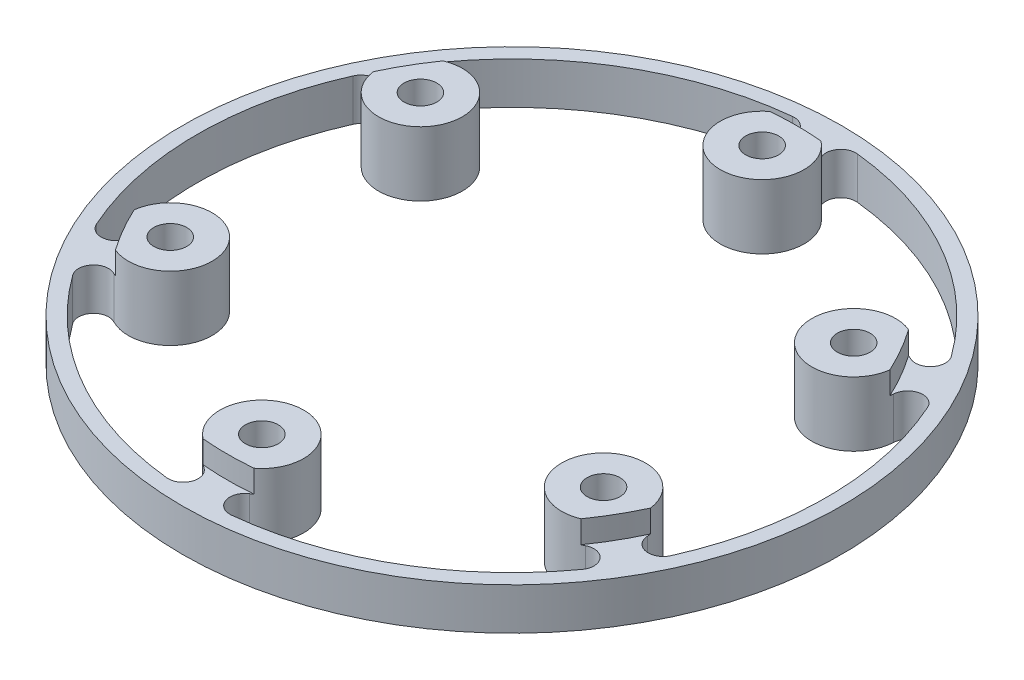
from build123d import *

# Parameters (mm, degrees)
SKETCH1_R             = 22
BASE_SHAPE_DEPTH      = 4.3
BASE_CUT_REACH        = 33.408
SKETCH4_R             = 2.1
MILLING_FILLETS_R     = 1
MIDDLE_START          = -1.5
SKETCH5_R             = 22
SKETCH5_R_2           = 19
MIDDLE_SLOT_CUT_DEPTH = 1.5
M2_SCREW_HOLES_REACH  = 33.408
SKETCH6_R             = 1.1
REMOVE_INNER_REACH    = 33.408


with BuildPart() as part:
    # Sketch1 → Base shape (new body)
    with BuildSketch(Plane(origin=(0, 0, 0), x_dir=(1, 0, 0), z_dir=(0, 1, 0))):
        Circle(SKETCH1_R)
    extrude(amount=BASE_SHAPE_DEPTH)

    # Sketch4 → Base cut (cut, up to next)
    with BuildSketch(Plane(origin=(0, 4.3, 0), x_dir=(1, 0, 0), z_dir=(0, 1, 0)), mode=Mode.PRIVATE) as base_cut_sk1:
        with BuildLine():
            Line((-0.5, 4.623040125), (-0.5, 13.945004537))
            ThreePointArc((-0.5, 13.945004537), (-2.746076212, 16.153131244), (-1.517286534, 19.053261901))
            ThreePointArc((-1.517286534, 19.053261901), (-1.115725557, 20.225230181), (-2.162133235, 20.888398212))
            ThreePointArc((-2.162133235, 20.888398212), (-10.500000003, 18.186533478), (-17.008816883, 12.316661408))
            ThreePointArc((-17.008816883, 12.316661408), (-16.957700355, 11.078861766), (-15.74196557, 10.84063963))
            ThreePointArc((-15.74196557, 10.84063963), (-12.615983904, 10.454737385), (-11.826728185, 7.40551497))
            Line((-11.826728185, 7.40551497), (-3.753670191, 2.744532765))
            ThreePointArc((-3.753670191, 2.744532765), (-2.325, 4.027018128), (-0.5, 4.623040125))
        make_face()
    base_cut_tool1 = extrude(base_cut_sk1.sketch, amount=-BASE_CUT_REACH, mode=Mode.PRIVATE) & part.part
    # Sketch4 → Base cut (cut, up to next)
    with BuildSketch(Plane(origin=(0, 4.3, 0), x_dir=(1, 0, 0), z_dir=(0, 1, 0)), mode=Mode.PRIVATE) as base_cut_sk2:
        with BuildLine():
            Line((0.5, 13.945004537), (0.5, 4.623040125))
            ThreePointArc((0.5, 4.623040125), (2.325, 4.027018128), (3.753670191, 2.744532765))
            Line((3.753670191, 2.744532765), (11.826728185, 7.40551497))
            ThreePointArc((11.826728185, 7.40551497), (12.615983941, 10.454737417), (15.741965657, 10.840639586))
            ThreePointArc((15.741965657, 10.840639586), (16.957700372, 11.078861786), (17.00881691, 12.316661371))
            ThreePointArc((17.00881691, 12.316661371), (10.500000058, 18.186533446), (2.162133314, 20.888398204))
            ThreePointArc((2.162133314, 20.888398204), (1.11572557, 20.225230219), (1.517286532, 19.053261902))
            ThreePointArc((1.517286532, 19.053261902), (2.746076212, 16.153131245), (0.5, 13.945004537))
        make_face()
    base_cut_tool2 = extrude(base_cut_sk2.sketch, amount=-BASE_CUT_REACH, mode=Mode.PRIVATE) & part.part
    # Sketch4 → Base cut (cut, up to next)
    with BuildSketch(Plane(origin=(0, 4.3, 0), x_dir=(1, 0, 0), z_dir=(0, 1, 0)), mode=Mode.PRIVATE) as base_cut_sk3:
        with BuildLine():
            ThreePointArc((-4.253670191, -1.878507361), (-4.65, 0), (-4.253670191, 1.878507361))
            Line((-4.253670191, 1.878507361), (-12.326728185, 6.539489567))
            ThreePointArc((-12.326728185, 6.539489567), (-15.362060141, 5.698393871), (-17.259252101, 8.212622326))
            ThreePointArc((-17.259252101, 8.212622326), (-18.073426017, 9.146368434), (-19.170950177, 8.571736657))
            ThreePointArc((-19.170950177, 8.571736657), (-21, -2.3e-08), (-19.170950158, -8.571736698))
            ThreePointArc((-19.170950158, -8.571736698), (-18.073425944, -9.146368421), (-17.259252096, -8.212622223))
            ThreePointArc((-17.259252096, -8.212622223), (-15.362060093, -5.698393854), (-12.326728185, -6.539489567))
            Line((-12.326728185, -6.539489567), (-4.253670191, -1.878507361))
        make_face()
    base_cut_tool3 = extrude(base_cut_sk3.sketch, amount=-BASE_CUT_REACH, mode=Mode.PRIVATE) & part.part
    # Sketch4 → Base cut (cut, up to next)
    with BuildSketch(Plane(origin=(0, 4.3, 0), x_dir=(1, 0, 0), z_dir=(0, 1, 0)), mode=Mode.PRIVATE) as base_cut_sk4:
        with BuildLine():
            Line((12.326728185, 6.539489567), (4.253670191, 1.878507361))
            ThreePointArc((4.253670191, 1.878507361), (4.65, 0), (4.253670191, -1.878507361))
            Line((4.253670191, -1.878507361), (12.326728185, -6.539489567))
            ThreePointArc((12.326728185, -6.539489567), (15.362060141, -5.698393871), (17.259252101, -8.212622326))
            ThreePointArc((17.259252101, -8.212622326), (18.07342595, -9.146368422), (19.170950121, -8.571736781))
            ThreePointArc((19.170950121, -8.571736781), (21, -9e-09), (19.170950128, 8.571736765))
            ThreePointArc((19.170950128, 8.571736765), (18.073425908, 9.146368414), (17.259252096, 8.212622223))
            ThreePointArc((17.259252096, 8.212622223), (15.362060093, 5.698393854), (12.326728185, 6.539489567))
        make_face()
    base_cut_tool4 = extrude(base_cut_sk4.sketch, amount=-BASE_CUT_REACH, mode=Mode.PRIVATE) & part.part
    # Sketch4 → Base cut (cut, up to next)
    with BuildSketch(Plane(origin=(0, 4.3, 0), x_dir=(1, 0, 0), z_dir=(0, 1, 0)), mode=Mode.PRIVATE) as base_cut_sk5:
        with BuildLine():
            ThreePointArc((-0.5, -4.623040125), (-2.325, -4.027018128), (-3.753670191, -2.744532765))
            Line((-3.753670191, -2.744532765), (-11.826728185, -7.40551497))
            ThreePointArc((-11.826728185, -7.40551497), (-12.615983918, -10.454737397), (-15.741965602, -10.840639614))
            ThreePointArc((-15.741965602, -10.840639614), (-16.957700382, -11.078861797), (-17.008816856, -12.316661445))
            ThreePointArc((-17.008816856, -12.316661445), (-10.500000018, -18.186533469), (-2.162133314, -20.888398204))
            ThreePointArc((-2.162133314, -20.888398204), (-1.115725572, -20.225230224), (-1.517286523, -19.053261908))
            ThreePointArc((-1.517286523, -19.053261908), (-2.746076213, -16.15313125), (-0.5, -13.945004537))
            Line((-0.5, -13.945004537), (-0.5, -4.623040125))
        make_face()
    base_cut_tool5 = extrude(base_cut_sk5.sketch, amount=-BASE_CUT_REACH, mode=Mode.PRIVATE) & part.part
    # Sketch4 → Base cut (cut, up to next)
    with BuildSketch(Plane(origin=(0, 4.3, 0), x_dir=(1, 0, 0), z_dir=(0, 1, 0)), mode=Mode.PRIVATE) as base_cut_sk6:
        with BuildLine():
            Line((11.826728185, -7.40551497), (3.753670191, -2.744532765))
            ThreePointArc((3.753670191, -2.744532765), (2.325, -4.027018128), (0.5, -4.623040125))
            Line((0.5, -4.623040125), (0.5, -13.945004537))
            ThreePointArc((0.5, -13.945004537), (2.746076211, -16.15313124), (1.51728654, -19.053261897))
            ThreePointArc((1.51728654, -19.053261897), (1.115725569, -20.225230215), (2.162133314, -20.888398204))
            ThreePointArc((2.162133314, -20.888398204), (10.499999986, -18.186533488), (17.008816813, -12.316661505))
            ThreePointArc((17.008816813, -12.316661505), (16.957700403, -11.078861822), (15.741965594, -10.840639618))
            ThreePointArc((15.741965594, -10.840639618), (12.615983914, -10.454737394), (11.826728185, -7.40551497))
        make_face()
    base_cut_tool6 = extrude(base_cut_sk6.sketch, amount=-BASE_CUT_REACH, mode=Mode.PRIVATE) & part.part
    # Sketch4 → Base cut (cut, up to next)
    with BuildSketch(Plane(origin=(0, 4.3, 0), x_dir=(1, 0, 0), z_dir=(0, 1, 0)), mode=Mode.PRIVATE) as base_cut_sk7:
        Circle(SKETCH4_R)
    base_cut_tool7 = extrude(base_cut_sk7.sketch, amount=-BASE_CUT_REACH, mode=Mode.PRIVATE) & part.part
    add(base_cut_tool1.solids().sort_by_distance((-6.978507, 4.3, -12.087128))[0], mode=Mode.SUBTRACT)
    add(base_cut_tool2.solids().sort_by_distance((6.978507, 4.3, -12.087128))[0], mode=Mode.SUBTRACT)
    add(base_cut_tool3.solids().sort_by_distance((-13.957013, 4.3, 0))[0], mode=Mode.SUBTRACT)
    add(base_cut_tool4.solids().sort_by_distance((13.957013, 4.3, 0))[0], mode=Mode.SUBTRACT)
    add(base_cut_tool5.solids().sort_by_distance((-6.978507, 4.3, 12.087128))[0], mode=Mode.SUBTRACT)
    add(base_cut_tool6.solids().sort_by_distance((6.978507, 4.3, 12.087128))[0], mode=Mode.SUBTRACT)
    add(base_cut_tool7.solids().sort_by_distance((0, 4.3, 0))[0], mode=Mode.SUBTRACT)

    # Milling fillets
    milling_fillets_edges = [part.edges().sort_by_distance(p)[0] for p in [
        (11.826728185, 2.15, 7.40551497),
        (0.5, 2.15, 4.623040125),
        (12.326728185, 2.15, -6.539489567),
        (-0.5, 2.15, -4.623040125),
        (11.826728185, 2.15, -7.40551497),
        (0.5, 2.15, -4.623040125),
        (4.253670191, 2.15, 1.878507361),
        (0.5, 2.15, -13.945004537),
        (-11.826728185, 2.15, 7.40551497),
        (0.5, 2.15, 13.945004537),
        (3.753670191, 2.15, 2.744532765),
        (-0.5, 2.15, 4.623040125),
        (-0.5, 2.15, -13.945004537),
        (-0.5, 2.15, 13.945004537),
        (12.326728185, 2.15, 6.539489567),
        (3.753670191, 2.15, -2.744532765),
        (-4.253670191, 2.15, 1.878507361),
        (-12.326728185, 2.15, 6.539489567),
        (-3.753670191, 2.15, -2.744532765),
        (-11.826728185, 2.15, -7.40551497),
        (-12.326728185, 2.15, -6.539489567),
        (-4.253670191, 2.15, -1.878507361),
        (4.253670191, 2.15, -1.878507361),
        (-3.753670191, 2.15, 2.744532765),
    ]]
    fillet(milling_fillets_edges, radius=MILLING_FILLETS_R)

    # Sketch5 → Middle slot cut (cut)
    with BuildSketch(Plane(origin=(0, 4.3, 0), x_dir=(1, 0, 0), z_dir=(0, 1, 0)).offset(MIDDLE_START)):
        Circle(SKETCH5_R)
        Circle(SKETCH5_R_2, mode=Mode.SUBTRACT)
    extrude(amount=MIDDLE_SLOT_CUT_DEPTH, mode=Mode.SUBTRACT)

    # Sketch6 → M2 screw holes (cut, up to next)
    with BuildSketch(Plane(origin=(0, 4.3, 0), x_dir=(1, 0, 0), z_dir=(0, 1, 0)), mode=Mode.PRIVATE) as m2_screw_holes_sk1:
        with Locations((0, 16.7)):
            Circle(SKETCH6_R)
    m2_screw_holes_tool1 = extrude(m2_screw_holes_sk1.sketch, amount=-M2_SCREW_HOLES_REACH, mode=Mode.PRIVATE) & part.part
    # Sketch6 → M2 screw holes (cut, up to next)
    with BuildSketch(Plane(origin=(0, 4.3, 0), x_dir=(1, 0, 0), z_dir=(0, 1, 0)), mode=Mode.PRIVATE) as m2_screw_holes_sk2:
        with Locations((14.462624243, 8.35)):
            Circle(SKETCH6_R)
    m2_screw_holes_tool2 = extrude(m2_screw_holes_sk2.sketch, amount=-M2_SCREW_HOLES_REACH, mode=Mode.PRIVATE) & part.part
    # Sketch6 → M2 screw holes (cut, up to next)
    with BuildSketch(Plane(origin=(0, 4.3, 0), x_dir=(1, 0, 0), z_dir=(0, 1, 0)), mode=Mode.PRIVATE) as m2_screw_holes_sk3:
        with Locations((14.462624243, -8.35)):
            Circle(SKETCH6_R)
    m2_screw_holes_tool3 = extrude(m2_screw_holes_sk3.sketch, amount=-M2_SCREW_HOLES_REACH, mode=Mode.PRIVATE) & part.part
    # Sketch6 → M2 screw holes (cut, up to next)
    with BuildSketch(Plane(origin=(0, 4.3, 0), x_dir=(1, 0, 0), z_dir=(0, 1, 0)), mode=Mode.PRIVATE) as m2_screw_holes_sk4:
        with Locations((0, -16.7)):
            Circle(SKETCH6_R)
    m2_screw_holes_tool4 = extrude(m2_screw_holes_sk4.sketch, amount=-M2_SCREW_HOLES_REACH, mode=Mode.PRIVATE) & part.part
    # Sketch6 → M2 screw holes (cut, up to next)
    with BuildSketch(Plane(origin=(0, 4.3, 0), x_dir=(1, 0, 0), z_dir=(0, 1, 0)), mode=Mode.PRIVATE) as m2_screw_holes_sk5:
        with Locations((-14.462624243, -8.35)):
            Circle(SKETCH6_R)
    m2_screw_holes_tool5 = extrude(m2_screw_holes_sk5.sketch, amount=-M2_SCREW_HOLES_REACH, mode=Mode.PRIVATE) & part.part
    # Sketch6 → M2 screw holes (cut, up to next)
    with BuildSketch(Plane(origin=(0, 4.3, 0), x_dir=(1, 0, 0), z_dir=(0, 1, 0)), mode=Mode.PRIVATE) as m2_screw_holes_sk6:
        with Locations((-14.462624243, 8.35)):
            Circle(SKETCH6_R)
    m2_screw_holes_tool6 = extrude(m2_screw_holes_sk6.sketch, amount=-M2_SCREW_HOLES_REACH, mode=Mode.PRIVATE) & part.part
    add(m2_screw_holes_tool1.solids().sort_by_distance((0, 4.3, -16.7))[0], mode=Mode.SUBTRACT)
    add(m2_screw_holes_tool2.solids().sort_by_distance((14.462624, 4.3, -8.35))[0], mode=Mode.SUBTRACT)
    add(m2_screw_holes_tool3.solids().sort_by_distance((14.462624, 4.3, 8.35))[0], mode=Mode.SUBTRACT)
    add(m2_screw_holes_tool4.solids().sort_by_distance((0, 4.3, 16.7))[0], mode=Mode.SUBTRACT)
    add(m2_screw_holes_tool5.solids().sort_by_distance((-14.462624, 4.3, 8.35))[0], mode=Mode.SUBTRACT)
    add(m2_screw_holes_tool6.solids().sort_by_distance((-14.462624, 4.3, -8.35))[0], mode=Mode.SUBTRACT)

    # Sketch9 → Remove inner (cut, up to next)
    with BuildSketch(Plane(origin=(0, 4.3, 0), x_dir=(1, 0, 0), z_dir=(0, 1, 0)), mode=Mode.PRIVATE) as remove_inner_sk1:
        with BuildLine():
            ThreePointArc((12.787298234, -6.106502114), (12.247842131, -6.303518255), (11.688967517, -6.171278273))
            Line((11.688967517, -6.171278273), (4.967454292, -2.290610804))
            ThreePointArc((4.967454292, -2.290610804), (4.544902316, -1.810458242), (4.499763267, -1.172446391))
            ThreePointArc((4.499763267, -1.172446391), (4.65, 0), (4.499763267, 1.172446391))
            ThreePointArc((4.499763267, 1.172446391), (4.544902316, 1.810458242), (4.967454292, 2.290610804))
            Line((4.967454292, 2.290610804), (11.688967517, 6.171278273))
            ThreePointArc((11.688967517, 6.171278273), (12.247842131, 6.303518255), (12.787298234, 6.106502114))
            ThreePointArc((12.787298234, 6.106502114), (12.037753113, 6.95), (11.682035076, 8.020874059))
            ThreePointArc((11.682035076, 8.020874059), (11.582928007, 7.455183299), (11.188967517, 7.037303677))
            Line((11.188967517, 7.037303677), (4.467454292, 3.156636207))
            ThreePointArc((4.467454292, 3.156636207), (3.840353988, 3.030771742), (3.265249993, 3.310686105))
            ThreePointArc((3.265249993, 3.310686105), (2.325, 4.027018128), (1.234513274, 4.483132496))
            ThreePointArc((1.234513274, 4.483132496), (0.704548328, 4.841229984), (0.5, 5.447247011))
            Line((0.5, 5.447247011), (0.5, 13.20858195))
            ThreePointArc((0.5, 13.20858195), (0.664914124, 13.758701554), (1.105263158, 14.127376174))
            ThreePointArc((1.105263158, 14.127376174), (0, 13.9), (-1.105263158, 14.127376174))
            ThreePointArc((-1.105263158, 14.127376174), (-0.664914124, 13.758701554), (-0.5, 13.20858195))
            Line((-0.5, 13.20858195), (-0.5, 5.447247011))
            ThreePointArc((-0.5, 5.447247011), (-0.704548328, 4.841229984), (-1.234513274, 4.483132496))
            ThreePointArc((-1.234513274, 4.483132496), (-2.325, 4.027018128), (-3.265249993, 3.310686105))
            ThreePointArc((-3.265249993, 3.310686105), (-3.840353988, 3.030771742), (-4.467454292, 3.156636207))
            Line((-4.467454292, 3.156636207), (-11.188967517, 7.037303677))
            ThreePointArc((-11.188967517, 7.037303677), (-11.582928007, 7.455183299), (-11.682035076, 8.020874059))
            ThreePointArc((-11.682035076, 8.020874059), (-12.037753113, 6.95), (-12.787298234, 6.106502114))
            ThreePointArc((-12.787298234, 6.106502114), (-12.247842131, 6.303518255), (-11.688967517, 6.171278273))
            Line((-11.688967517, 6.171278273), (-4.967454292, 2.290610804))
            ThreePointArc((-4.967454292, 2.290610804), (-4.544902316, 1.810458242), (-4.499763267, 1.172446391))
            ThreePointArc((-4.499763267, 1.172446391), (-4.65, 0), (-4.499763267, -1.172446391))
            ThreePointArc((-4.499763267, -1.172446391), (-4.544902316, -1.810458242), (-4.967454292, -2.290610804))
            Line((-4.967454292, -2.290610804), (-11.688967517, -6.171278273))
            ThreePointArc((-11.688967517, -6.171278273), (-12.247842131, -6.303518255), (-12.787298234, -6.106502114))
            ThreePointArc((-12.787298234, -6.106502114), (-12.037753113, -6.95), (-11.682035076, -8.020874059))
            ThreePointArc((-11.682035076, -8.020874059), (-11.582928007, -7.455183299), (-11.188967517, -7.037303677))
            Line((-11.188967517, -7.037303677), (-4.467454292, -3.156636207))
            ThreePointArc((-4.467454292, -3.156636207), (-3.840353988, -3.030771742), (-3.265249993, -3.310686105))
            ThreePointArc((-3.265249993, -3.310686105), (-2.325, -4.027018128), (-1.234513274, -4.483132496))
            ThreePointArc((-1.234513274, -4.483132496), (-0.704548328, -4.841229984), (-0.5, -5.447247011))
            Line((-0.5, -5.447247011), (-0.5, -13.20858195))
            ThreePointArc((-0.5, -13.20858195), (-0.664914124, -13.758701554), (-1.105263158, -14.127376174))
            ThreePointArc((-1.105263158, -14.127376174), (0, -13.9), (1.105263158, -14.127376174))
            ThreePointArc((1.105263158, -14.127376174), (0.664914124, -13.758701554), (0.5, -13.20858195))
            Line((0.5, -13.20858195), (0.5, -5.447247011))
            ThreePointArc((0.5, -5.447247011), (0.704548328, -4.841229984), (1.234513274, -4.483132496))
            ThreePointArc((1.234513274, -4.483132496), (2.325, -4.027018128), (3.265249993, -3.310686105))
            ThreePointArc((3.265249993, -3.310686105), (3.840353988, -3.030771742), (4.467454292, -3.156636207))
            Line((4.467454292, -3.156636207), (11.188967517, -7.037303677))
            ThreePointArc((11.188967517, -7.037303677), (11.582928007, -7.455183299), (11.682035076, -8.020874059))
            ThreePointArc((11.682035076, -8.020874059), (12.037753113, -6.95), (12.787298234, -6.106502114))
        make_face()
    remove_inner_tool1 = extrude(remove_inner_sk1.sketch, amount=-REMOVE_INNER_REACH, mode=Mode.PRIVATE) & part.part
    add(remove_inner_tool1.solids().sort_by_distance((0, 4.3, 0))[0], mode=Mode.SUBTRACT)


solid = part.part
